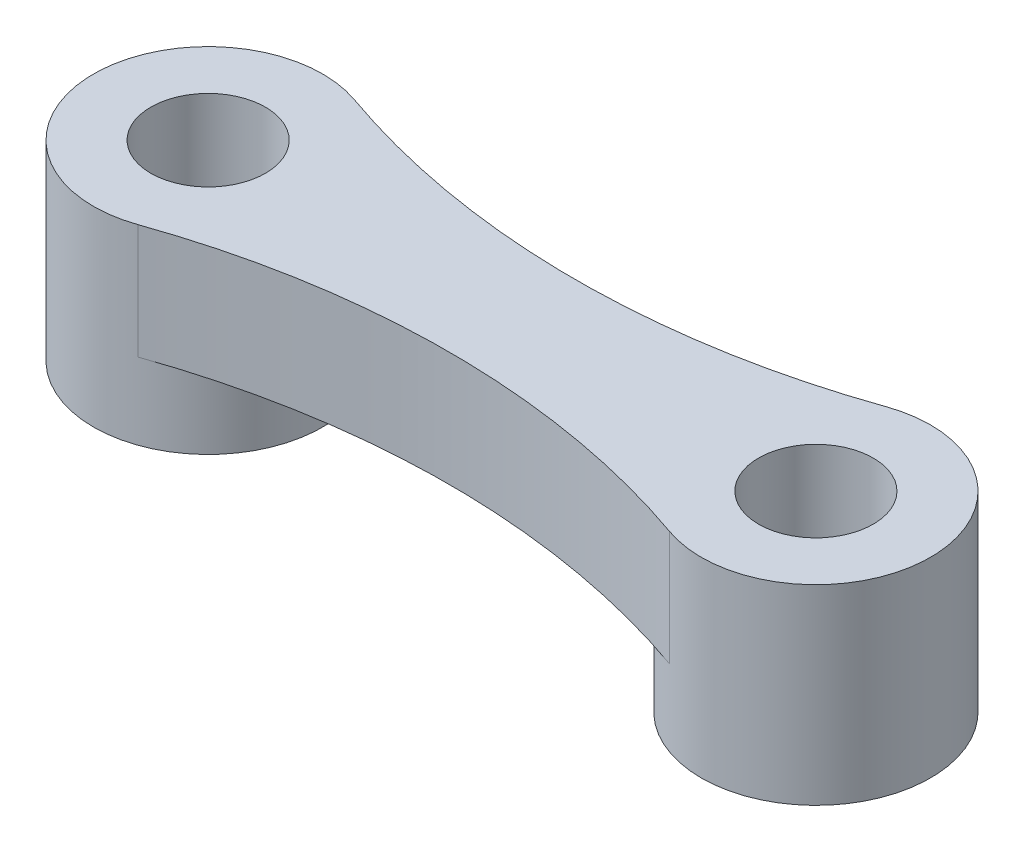
from build123d import *
from build123d.topology import SkipClean

# Parameters (mm, degrees)
SKETCH1_R           = 1.5
BOSS_EXTRUDE1_DEPTH = 3
SKETCH2_OUTSIDE_W   = 28.48
SKETCH2_OUTSIDE_H   = 12.58
CUT_EXTRUDE1_DEPTH  = 12.743189516
BOSS_EXTRUDE2_START = -3
SKETCH3_R           = 1.5
BOSS_EXTRUDE2_DEPTH = 2


with BuildPart() as part:
    # Sketch1 → Boss-Extrude1 (new body)
    with BuildSketch(Plane(origin=(0, 0, 0), x_dir=(1, 0, 0), z_dir=(0, 1, 0))):
        with BuildLine():
            Line((-7.95, 3), (7.95, 3))
            ThreePointArc((7.95, 3), (10.95, 0), (7.95, -3))
            Line((7.95, -3), (-7.95, -3))
            ThreePointArc((-7.95, -3), (-10.95, 0), (-7.95, 3))
        make_face()
        with Locations(Location((-7.95, 0, 0), (0, 0, 270))):
            Circle(SKETCH1_R, mode=Mode.SUBTRACT)
        with Locations(Location((7.95, 0, 0), (0, 0, 270))):
            Circle(SKETCH1_R, mode=Mode.SUBTRACT)
    extrude(amount=BOSS_EXTRUDE1_DEPTH)

    # Sketch2 outside → Cut-Extrude1 (cut, through all)
    with SkipClean():  # the faces are left unmerged after this step: merging them gives an invalid solid
        with BuildSketch(Plane(origin=(0, 3, 0), x_dir=(1, 0, 0), z_dir=(0, 1, 0))):
            Rectangle(SKETCH2_OUTSIDE_W, SKETCH2_OUTSIDE_H)
            with BuildLine():
                ThreePointArc((-6.95625, 2.830629071), (-10.95, 0), (-6.95625, -2.830629071))
                ThreePointArc((-6.95625, -2.830629071), (0, -1.645032568), (6.95625, -2.830629071))
                ThreePointArc((6.95625, -2.830629071), (10.95, 0), (6.95625, 2.830629071))
                ThreePointArc((6.95625, 2.830629071), (0, 1.645032568), (-6.95625, 2.830629071))
            make_face(mode=Mode.SUBTRACT)
        extrude(amount=-CUT_EXTRUDE1_DEPTH, mode=Mode.SUBTRACT)

    # Sketch3 → Boss-Extrude2 (add)
    with SkipClean():  # the faces are left unmerged after this step: merging them gives an invalid solid
        with BuildSketch(Plane(origin=(0, 3, 0), x_dir=(1, 0, 0), z_dir=(0, 1, 0)).offset(BOSS_EXTRUDE2_START)):
            with BuildLine():
                ThreePointArc((-6.95625, -2.830629071), (-5.502424669, -1.734755026), (-4.95, 0))
                ThreePointArc((-4.95, 0), (-5.502424669, 1.734755026), (-6.95625, 2.830629071))
                ThreePointArc((-6.95625, 2.830629071), (-10.95, 0), (-6.95625, -2.830629071))
            make_face()
            with Locations(Location((-7.95, 0, 0), (0, 0, 270))):
                Circle(SKETCH3_R, mode=Mode.SUBTRACT)
            with BuildLine():
                ThreePointArc((6.95625, -2.830629071), (9.684755026, -2.447575331), (10.95, 0))
                ThreePointArc((10.95, 0), (9.684755026, 2.447575331), (6.95625, 2.830629071))
                ThreePointArc((6.95625, 2.830629071), (4.95, 0), (6.95625, -2.830629071))
            make_face()
            with Locations(Location((7.95, 0, 0), (0, 0, 270))):
                Circle(SKETCH3_R, mode=Mode.SUBTRACT)
        extrude(amount=-BOSS_EXTRUDE2_DEPTH)


solid = part.part
